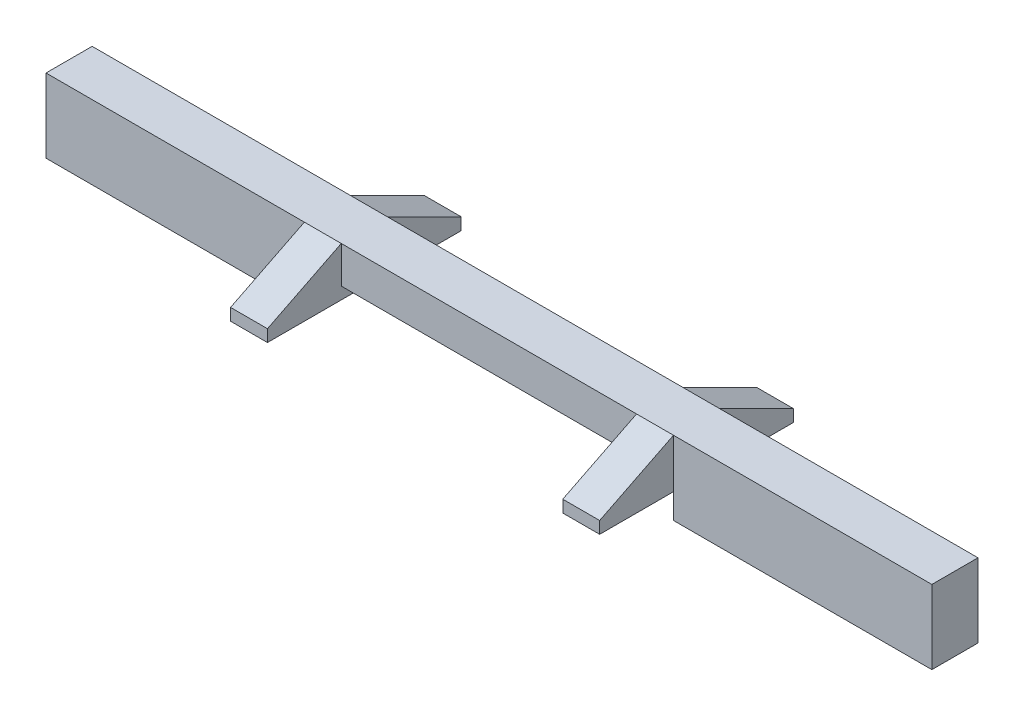
from build123d import *

# Parameters (mm, degrees)
BOSS_EXTRUDE1_DEPTH = 1.25
SKETCH2_W           = 1
SKETCH2_H           = 0.325
BOSS_EXTRUDE2_DEPTH = 2
SKETCH3_W           = 1
SKETCH3_H           = 0.325
BOSS_EXTRUDE3_DEPTH = 2
BOSS_EXTRUDE7_DEPTH = 1
BOSS_EXTRUDE8_DEPTH = 1


with BuildPart() as part:
    # Sketch1 → Boss-Extrude1 (new body)
    with BuildSketch(Plane.XY):
        Polygon((1, 0), (9, 0), (9, -0.325), (10, -0.325), (10, -1), (17, -1), (17, 1), (10, 1), (0, 1), (-7, 1), (-7, -1), (0, -1), (0, -0.325), (1, -0.325), align=None)
    extrude(amount=BOSS_EXTRUDE1_DEPTH)

    # Sketch2 → Boss-Extrude2 (add)
    with BuildSketch(Plane.XY.offset(1.25)):
        with Locations((0.5, -0.1625)):
            Rectangle(SKETCH2_W, SKETCH2_H)
        with Locations((9.5, -0.1625)):
            Rectangle(SKETCH2_W, SKETCH2_H)
    extrude(amount=BOSS_EXTRUDE2_DEPTH)

    # Sketch3 → Boss-Extrude3 (add)
    with BuildSketch(Plane(origin=(0, 0, 0), x_dir=(-1, 0, 0), z_dir=(0, 0, -1))):
        with Locations((-9.5, -0.1625)):
            Rectangle(SKETCH3_W, SKETCH3_H)
        with Locations((-0.5, -0.1625)):
            Rectangle(SKETCH3_W, SKETCH3_H)
    extrude(amount=BOSS_EXTRUDE3_DEPTH)

    # Sketch7 → Boss-Extrude7 (add)
    with BuildSketch(Plane(origin=(10, 0, 0), x_dir=(0, 0, -1), z_dir=(1, 0, 0))):
        Polygon((-3.25, 0), (-1.25, 1), (-1.25, 0), (-1.25, -0.325), (-3.25, -0.325), align=None)
        Polygon((2, 0), (0, 1), (0, 0), align=None)
    extrude(amount=-BOSS_EXTRUDE7_DEPTH)

    # Sketch8 → Boss-Extrude8 (add)
    with BuildSketch(Plane.ZY):
        Polygon((-2, 0), (0, 1), (0, 0), align=None)
        Polygon((1.25, 1), (1.25, 0), (3.25, 0), align=None)
    extrude(amount=-BOSS_EXTRUDE8_DEPTH)


solid = part.part
